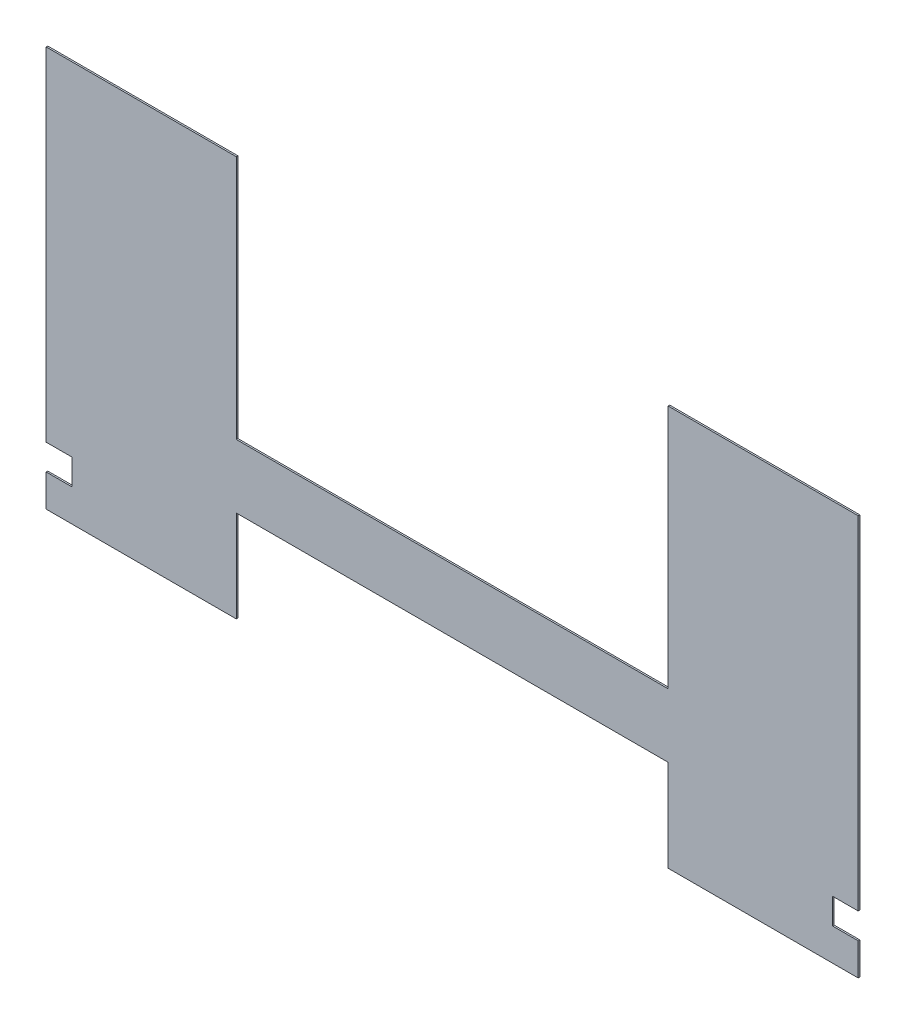
from build123d import *

# Parameters (mm, degrees)
BOSS_EXTRUDE1_DEPTH = 1.5875
SKETCH2_W           = 25.4
SKETCH2_H           = 25.4
CUT_EXTRUDE1_DEPTH  = 2.5875
SKETCH3_W           = 25.4
SKETCH3_H           = 25.4
CUT_EXTRUDE2_DEPTH  = 2.5875


with BuildPart() as part:
    # Sketch1 → Boss-Extrude1 (new body)
    with BuildSketch(Plane.XY):
        Polygon((-400.05, 241.3), (-400.05, -153.162), (-212.725, -153.162), (-212.725, -62.738), (212.725, -62.738), (212.725, -153.162), (400.05, -153.162), (400.05, 241.3), (212.725, 241.3), (212.725, 0), (-212.725, 0), (-212.725, 241.3), align=None)
    extrude(amount=BOSS_EXTRUDE1_DEPTH)

    # Sketch2 → Cut-Extrude1 (cut, through all)
    with BuildSketch(Plane(origin=(0, 0, 0), x_dir=(-1, 0, 0), z_dir=(0, 0, -1))):
        with Locations((-387.35, -108.712)):
            Rectangle(SKETCH2_W, SKETCH2_H)
    extrude(amount=-CUT_EXTRUDE1_DEPTH, mode=Mode.SUBTRACT)

    # Sketch3 → Cut-Extrude2 (cut, through all)
    with BuildSketch(Plane(origin=(0, 0, 0), x_dir=(-1, 0, 0), z_dir=(0, 0, -1))):
        with Locations((387.35, -108.712)):
            Rectangle(SKETCH3_W, SKETCH3_H)
    extrude(amount=-CUT_EXTRUDE2_DEPTH, mode=Mode.SUBTRACT)


solid = part.part
